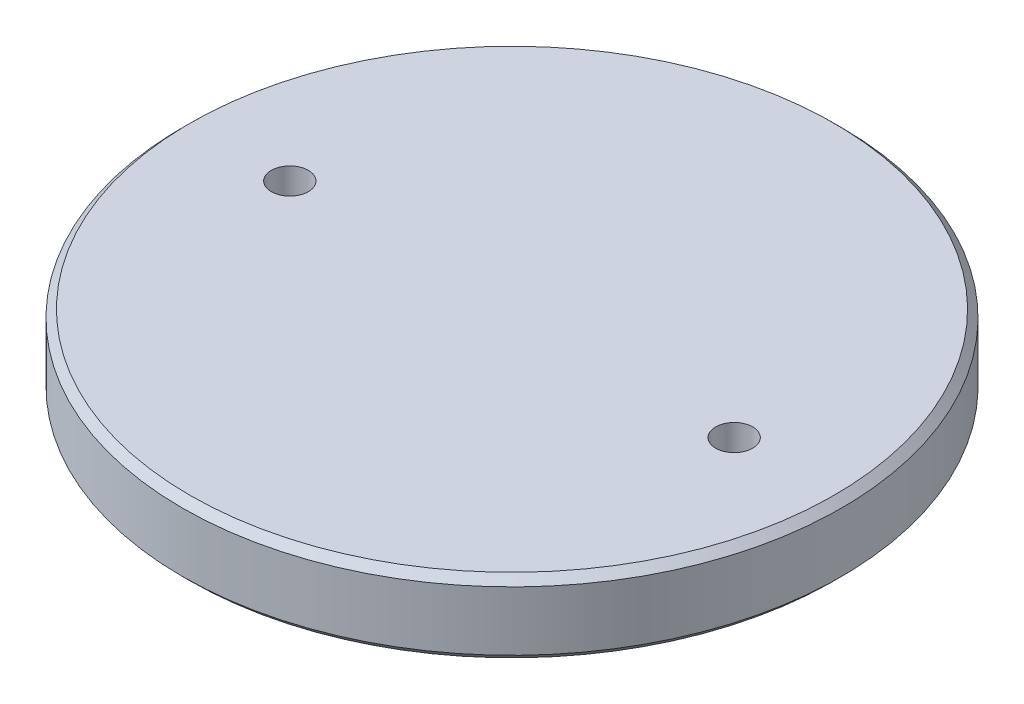
from build123d import *

# Parameters (mm, degrees)
SKETCH1_R           = 56.515
BOSS_EXTRUDE1_DEPTH = 12.7
CHAMFER1_SIZE       = 1.27
SKETCH2_R           = 50.165
BOSS_EXTRUDE2_DEPTH = 3.175
CHAMFER2_SIZE       = 1.27
SKETCH3_R           = 3.175
CUT_EXTRUDE1_DEPTH  = 16.875


with BuildPart() as part:
    # Sketch1 → Boss-Extrude1 (new body)
    with BuildSketch(Plane(origin=(0, 0, 0), x_dir=(1, 0, 0), z_dir=(0, 1, 0))):
        Circle(SKETCH1_R)
    extrude(amount=BOSS_EXTRUDE1_DEPTH)

    # Chamfer1
    chamfer1_edges = [part.edges().sort_by_distance(p)[0] for p in [
        (-56.515, 0, 0),
        (-56.515, 12.7, 0),
    ]]
    chamfer(chamfer1_edges, length=CHAMFER1_SIZE)

    # Sketch2 → Boss-Extrude2 (add)
    with BuildSketch(Plane.XZ):
        Circle(SKETCH2_R)
    extrude(amount=BOSS_EXTRUDE2_DEPTH)

    # Chamfer2
    chamfer2_edges = [part.edges().sort_by_distance(p)[0] for p in [
        (-50.165, -3.175, 0),
    ]]
    chamfer(chamfer2_edges, length=CHAMFER2_SIZE)

    # Sketch3 → Cut-Extrude1 (cut, through all)
    with BuildSketch(Plane(origin=(0, 12.7, 0), x_dir=(1, 0, 0), z_dir=(0, 1, 0))):
        with Locations((-38.1, 0)):
            Circle(SKETCH3_R)
        with Locations((38.1, 0)):
            Circle(SKETCH3_R)
    extrude(amount=-CUT_EXTRUDE1_DEPTH, mode=Mode.SUBTRACT)


solid = part.part
